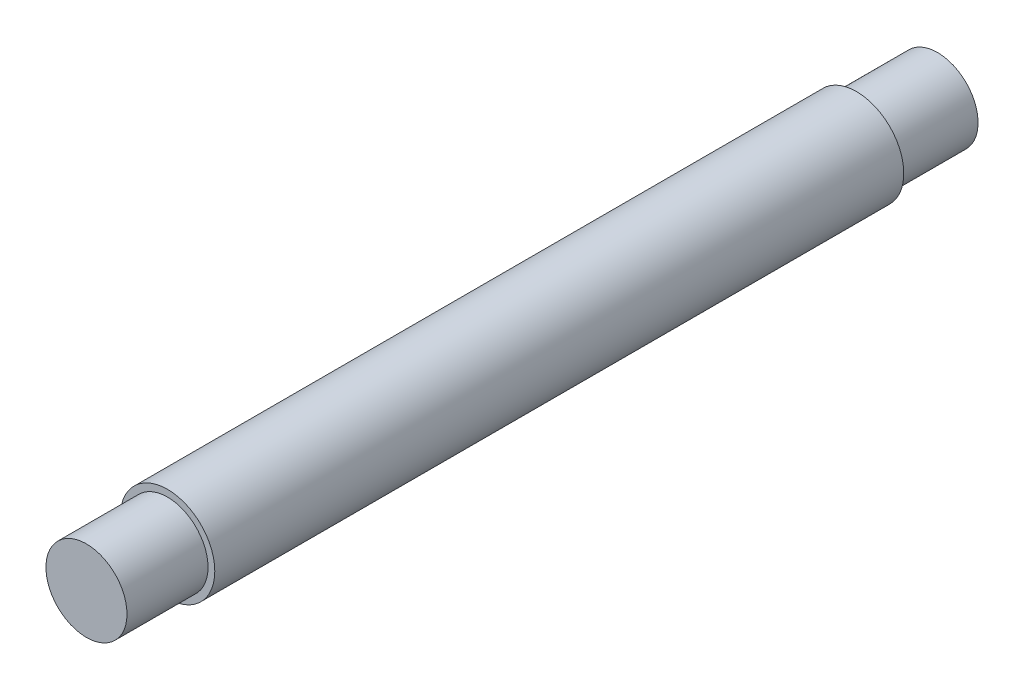
from build123d import *

# Parameters (mm, degrees)
SKETCH_1_R          = 3.5
EXTRUDE_1_DEPTH     = 63
SKETCH_2_R          = 5.249939155
SKETCH_2_R_2        = 3
CUT_EXTRUDE_1_DEPTH = 6
SKETCH_3_R          = 5.960650936
SKETCH_3_R_2        = 3
CUT_EXTRUDE_2_DEPTH = 6


with BuildPart() as part:
    # ｽｹｯﾁ1 → ﾎﾞｽ - 押し出し1 (new body)
    with BuildSketch(Plane.XY):
        Circle(SKETCH_1_R)
    extrude(amount=EXTRUDE_1_DEPTH)

    # ｽｹｯﾁ2 → ｶｯﾄ - 押し出し1 (cut)
    with BuildSketch(Plane.XY.offset(63)):
        Circle(SKETCH_2_R)
        Circle(SKETCH_2_R_2, mode=Mode.SUBTRACT)
    extrude(amount=-CUT_EXTRUDE_1_DEPTH, mode=Mode.SUBTRACT)

    # ｽｹｯﾁ3 → ｶｯﾄ - 押し出し2 (cut)
    with BuildSketch(Plane(origin=(0, 0, 0), x_dir=(-1, 0, 0), z_dir=(0, 0, -1))):
        Circle(SKETCH_3_R)
        Circle(SKETCH_3_R_2, mode=Mode.SUBTRACT)
    extrude(amount=-CUT_EXTRUDE_2_DEPTH, mode=Mode.SUBTRACT)


solid = part.part
